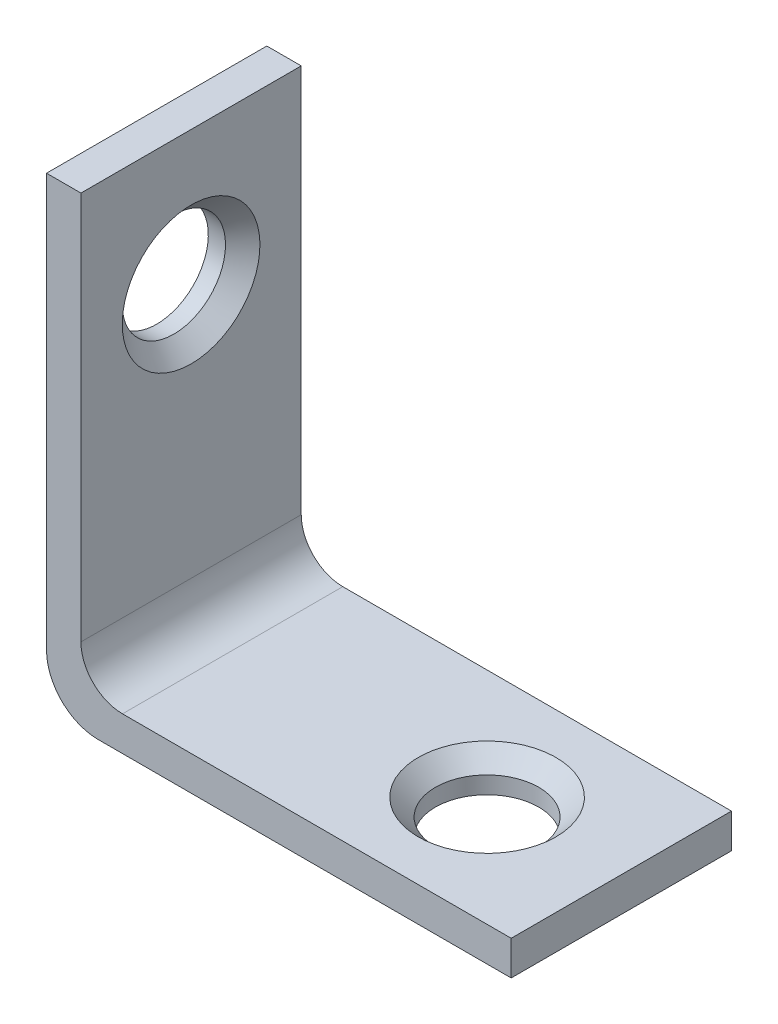
from build123d import *

# Parameters (mm, degrees)
BOSS_EXTRUDE1_DEPTH = 6.4
SKETCH2_R           = 3
CUT_EXTRUDE1_DEPTH  = 3
SKETCH3_R           = 3
CUT_EXTRUDE2_DEPTH  = 3
CHAMFER1_SIZE       = 1


with BuildPart() as part:
    # Sketch1 → Boss-Extrude1 (new body, symmetric)
    with BuildSketch(Plane.XY):
        with BuildLine():
            Line((3, 0), (27, 0))
            Line((27, 0), (27, 2))
            Line((27, 2), (4.414213562, 2))
            ThreePointArc((4.414213562, 2), (2.707106781, 2.707106781), (2, 4.414213562))
            Line((2, 4.414213562), (2, 27))
            Line((2, 27), (0, 27))
            Line((0, 27), (0, 3))
            ThreePointArc((0, 3), (0.878679656, 0.878679656), (3, 0))
        make_face()
    extrude(amount=BOSS_EXTRUDE1_DEPTH, both=True)

    # Sketch2 → Cut-Extrude1 (cut, through all)
    with BuildSketch(Plane(origin=(0, 2, 0), x_dir=(1, 0, 0), z_dir=(0, 1, 0))):
        with Locations((19.2, 0)):
            Circle(SKETCH2_R)
    extrude(amount=-CUT_EXTRUDE1_DEPTH, mode=Mode.SUBTRACT)

    # Sketch3 → Cut-Extrude2 (cut, through all)
    with BuildSketch(Plane(origin=(2, 0, 0), x_dir=(0, 0, -1), z_dir=(1, 0, 0))):
        with Locations((0, 19.2)):
            Circle(SKETCH3_R)
    extrude(amount=-CUT_EXTRUDE2_DEPTH, mode=Mode.SUBTRACT)

    # Chamfer1
    chamfer1_edges = [part.edges().sort_by_distance(p)[0] for p in [
        (16.2, 2, 0),
        (2, 19.2, 3),
    ]]
    chamfer(chamfer1_edges, length=CHAMFER1_SIZE)


solid = part.part
